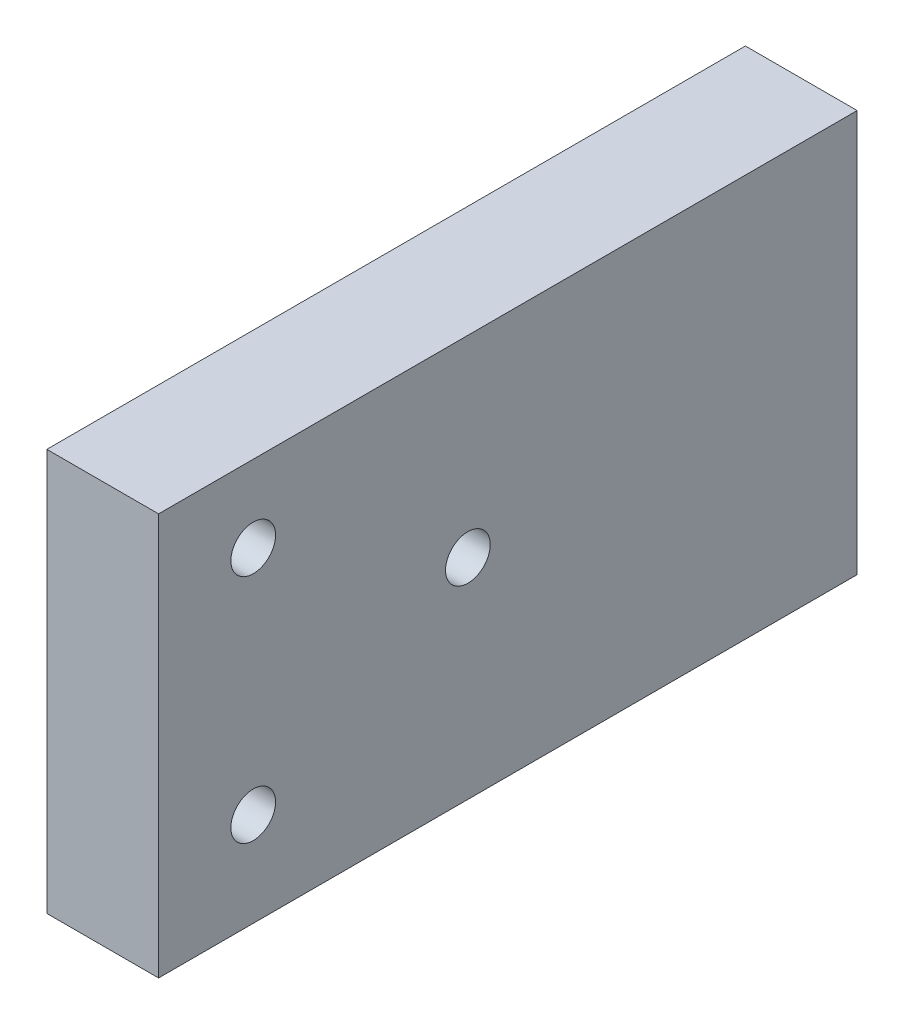
from build123d import *

# Parameters (mm, degrees)
CROQUIS1_W              = 8
CROQUIS1_H              = 28.768453788
SALIENTE_EXTRUIR1_DEPTH = 50
CORTAR_EXTRUIR1_REACH   = 10
CROQUIS3_R              = 1.6
CROQUIS4_R              = 1.95
CORTAR_EXTRUIR2_DEPTH   = 22


with BuildPart() as part:
    # Croquis1 → Saliente-Extruir1 (new body)
    with BuildSketch(Plane.XY):
        with Locations((90, 9.384226894)):
            Rectangle(CROQUIS1_W, CROQUIS1_H)
    extrude(amount=SALIENTE_EXTRUIR1_DEPTH)

    # Croquis3 → Cortar-Extruir1 (cut, up to next)
    with BuildSketch(Plane(origin=(86, 0, 0), x_dir=(0, 0, -1), z_dir=(1, 0, 0)), mode=Mode.PRIVATE) as cortar_extruir1_sk1:
        with Locations((-43.227046774, 1.729227937)):
            Circle(CROQUIS3_R)
    cortar_extruir1_tool1 = extrude(cortar_extruir1_sk1.sketch, amount=CORTAR_EXTRUIR1_REACH, mode=Mode.PRIVATE) & part.part
    add(cortar_extruir1_tool1.solids().sort_by_distance((86, 1.729228, 43.227047))[0], mode=Mode.SUBTRACT)
    # Croquis3 → Cortar-Extruir1 (cut, up to next)
    with BuildSketch(Plane(origin=(86, 0, 0), x_dir=(0, 0, -1), z_dir=(1, 0, 0)), mode=Mode.PRIVATE) as cortar_extruir1_sk2:
        with Locations((-27.863523387, 10)):
            Circle(CROQUIS3_R)
    cortar_extruir1_tool2 = extrude(cortar_extruir1_sk2.sketch, amount=CORTAR_EXTRUIR1_REACH, mode=Mode.PRIVATE) & part.part
    add(cortar_extruir1_tool2.solids().sort_by_distance((86, 10, 27.863523))[0], mode=Mode.SUBTRACT)
    # Croquis3 → Cortar-Extruir1 (cut, up to next)
    with BuildSketch(Plane(origin=(86, 0, 0), x_dir=(0, 0, -1), z_dir=(1, 0, 0)), mode=Mode.PRIVATE) as cortar_extruir1_sk3:
        with Locations((-43.227046774, 18.270772063)):
            Circle(CROQUIS3_R)
    cortar_extruir1_tool3 = extrude(cortar_extruir1_sk3.sketch, amount=CORTAR_EXTRUIR1_REACH, mode=Mode.PRIVATE) & part.part
    add(cortar_extruir1_tool3.solids().sort_by_distance((86, 18.270772, 43.227047))[0], mode=Mode.SUBTRACT)

    # Croquis4 → Cortar-Extruir2 (cut)
    with BuildSketch(Plane(origin=(0, 0, 0), x_dir=(-1, 0, 0), z_dir=(0, 0, -1))):
        with Locations((-90.073577236, 1)):
            Circle(CROQUIS4_R)
        with Locations((-90, 9.384226894)):
            Circle(CROQUIS4_R)
        with Locations((-90, 17.768453788)):
            Circle(CROQUIS4_R)
    extrude(amount=-CORTAR_EXTRUIR2_DEPTH, mode=Mode.SUBTRACT)


solid = part.part
